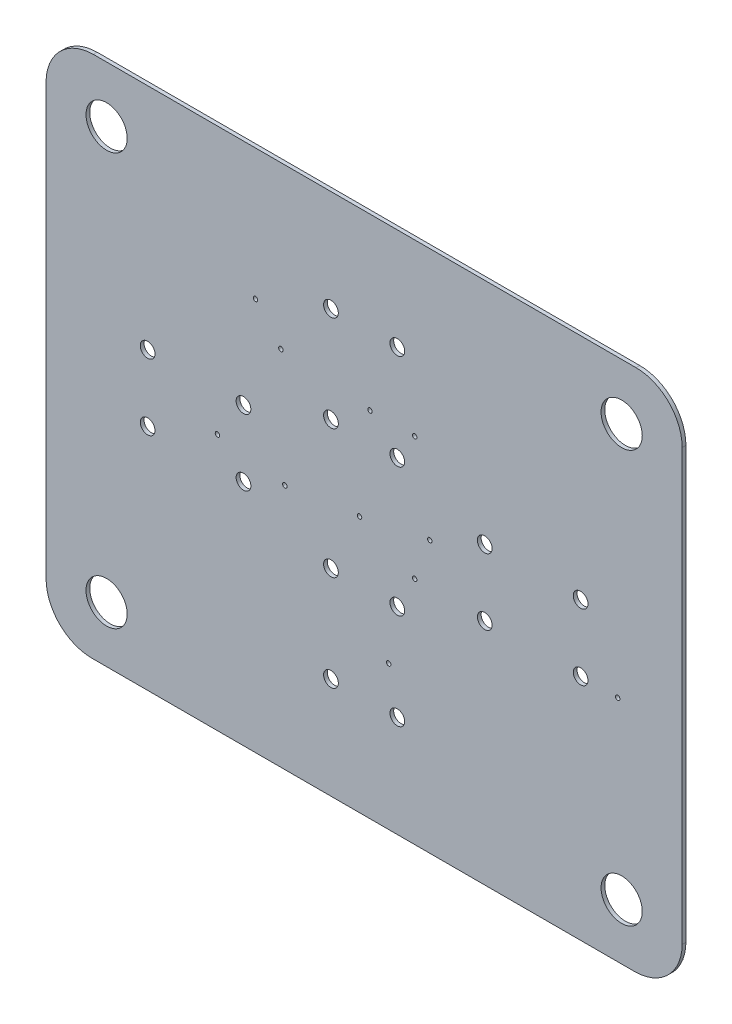
from build123d import *

# Parameters (mm, degrees)
BOARD_OUTLINE_START = 0.034
BOARD_OUTLINE_DEPTH = 0.254
SKETCH2_R           = 1.397
NPTH_DEPTH          = 1.288
SKETCH3_R           = 0.5
SKETCH3_R_2         = 0.1525
PTH_DEPTH           = 1.288


with BuildPart() as part:
    # Sketch1 → Board_Outline (new body)
    with BuildSketch(Plane.XY.offset(BOARD_OUTLINE_START)):
        with BuildLine():
            Line((-21.565, 14.63), (-21.565, -14.63))
            ThreePointArc((-21.565, -14.63), (-20.655306988, -16.845306988), (-18.44, -17.755))
            Line((-18.44, -17.755), (18.364, -17.755))
            ThreePointArc((18.364, -17.755), (20.620097217, -16.810097217), (21.565, -14.554))
            Line((21.565, -14.554), (21.565, 14.63))
            ThreePointArc((21.565, 14.63), (20.651306754, 16.841306754), (18.44, 17.755))
            Line((18.44, 17.755), (-18.364, 17.755))
            ThreePointArc((-18.364, 17.755), (-20.588664714, 16.8318444), (-21.565, 14.63))
        make_face()
    extrude(amount=BOARD_OUTLINE_DEPTH)

    # Sketch2 → NPTH (cut, through all)
    with BuildSketch(Plane.XY):
        with Locations((-17.462, 13.97)):
            Circle(SKETCH2_R)
        with Locations((17.462, -13.97)):
            Circle(SKETCH2_R)
        with Locations((17.462, 13.97)):
            Circle(SKETCH2_R)
        with Locations((-17.462, -13.97)):
            Circle(SKETCH2_R)
    extrude(amount=NPTH_DEPTH, mode=Mode.SUBTRACT)

    # Sketch3 → PTH (cut, through all)
    with BuildSketch(Plane.XY):
        with Locations((-2.25, 10.87)):
            Circle(SKETCH3_R)
        with Locations((2.25, 10.87)):
            Circle(SKETCH3_R)
        with Locations((2.25, 4.37)):
            Circle(SKETCH3_R)
        with Locations((-2.25, 4.37)):
            Circle(SKETCH3_R)
        with Locations((-8.18, 2.25)):
            Circle(SKETCH3_R)
        with Locations((-8.18, -2.25)):
            Circle(SKETCH3_R)
        with Locations((-14.68, -2.25)):
            Circle(SKETCH3_R)
        with Locations((-14.68, 2.25)):
            Circle(SKETCH3_R)
        with Locations((-2.25, -4.37)):
            Circle(SKETCH3_R)
        with Locations((2.25, -4.37)):
            Circle(SKETCH3_R)
        with Locations((2.25, -10.87)):
            Circle(SKETCH3_R)
        with Locations((-2.25, -10.87)):
            Circle(SKETCH3_R)
        with Locations((14.68, 2.25)):
            Circle(SKETCH3_R)
        with Locations((14.68, -2.25)):
            Circle(SKETCH3_R)
        with Locations((8.18, -2.25)):
            Circle(SKETCH3_R)
        with Locations((8.18, 2.25)):
            Circle(SKETCH3_R)
        with Locations((4.45, 0.635)):
            Circle(SKETCH3_R_2)
        with Locations((-7.366, 8.89)):
            Circle(SKETCH3_R_2)
        with Locations((3.43, -2.148)):
            Circle(SKETCH3_R_2)
        with Locations((3.43, 6.223)):
            Circle(SKETCH3_R_2)
        with Locations((-9.944, -0.354)):
            Circle(SKETCH3_R_2)
        with Locations((-0.313, -0.354)):
            Circle(SKETCH3_R_2)
        with Locations((0.398, 6.223)):
            Circle(SKETCH3_R_2)
        with Locations((-5.377, -1.065)):
            Circle(SKETCH3_R_2)
        with Locations((17.196, -2.25)):
            Circle(SKETCH3_R_2)
        with Locations((1.666, -8.001)):
            Circle(SKETCH3_R_2)
        with Locations((-5.645, 6.807)):
            Circle(SKETCH3_R_2)
    extrude(amount=PTH_DEPTH, mode=Mode.SUBTRACT)


solid = part.part
